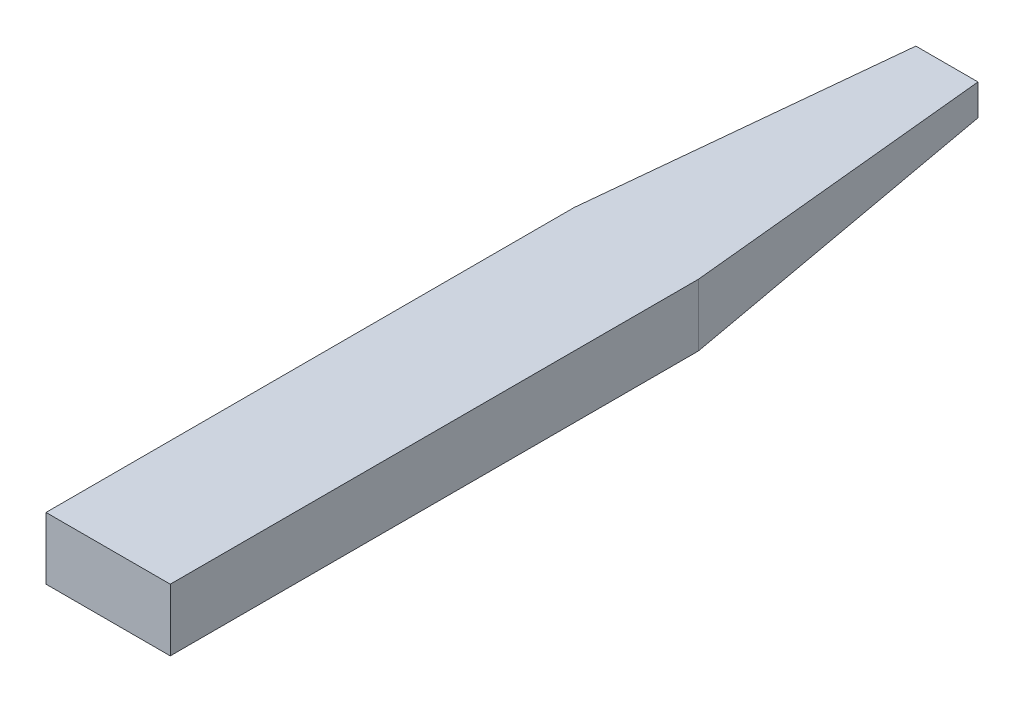
from build123d import *

# Parameters (mm, degrees)
SKETCH1_W           = 101.6
SKETCH1_H           = 50.8
BOSS_EXTRUDE1_DEPTH = 431.8
SKETCH2_W           = 101.6
SKETCH2_H           = 50.8
SKETCH3_W           = 50.8
SKETCH3_H           = 25.4


with BuildPart() as part:
    # Sketch1 → Boss-Extrude1 (new body)
    with BuildSketch(Plane.XY):
        with Locations((50.8, 25.4)):
            Rectangle(SKETCH1_W, SKETCH1_H)
    extrude(amount=BOSS_EXTRUDE1_DEPTH)

    # Sketch2 → Loft1 section 0
    with BuildSketch(Plane.XY):
        with Locations((50.8, 25.4)):
            Rectangle(SKETCH2_W, SKETCH2_H)
    # Sketch3 → Loft1 section 1
    with BuildSketch(Plane(origin=(0, 0, -254), x_dir=(-1, 0, 0), z_dir=(0, 0, -1))):
        with Locations((-50.8, 38.1)):
            Rectangle(SKETCH3_W, SKETCH3_H)
    loft()


solid = part.part
